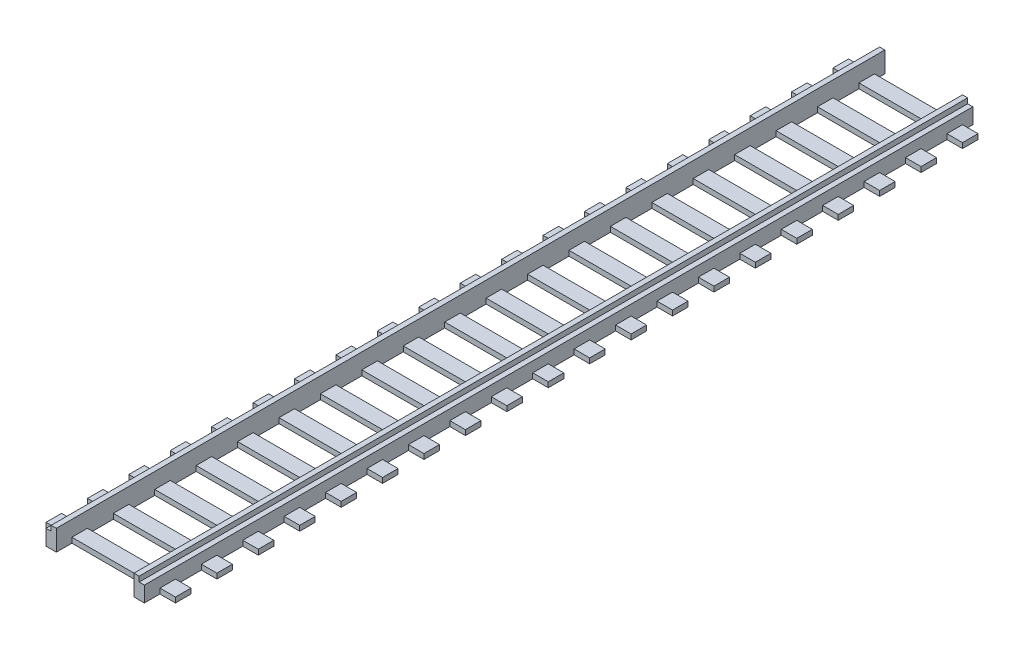
from build123d import *

# Parameters (mm, degrees)
SKETCH1_W             = 1
SKETCH1_H             = 160
BOSS_EXTRUDE1_DEPTH   = 4
BOSS_EXTRUDE1_2_DEPTH = 4
SKETCH2_W             = 1
SKETCH2_H             = 160
BOSS_EXTRUDE2_DEPTH   = 3
SKETCH3_W             = 25
SKETCH3_H             = 3
BOSS_EXTRUDE3_DEPTH   = 1


with BuildPart() as part:
    # Sketch1 → Boss-Extrude1 (new body)
    with BuildSketch(Plane(origin=(0, 0, 0), x_dir=(1, 0, 0), z_dir=(0, 1, 0))):
        with Locations((-43.187559699, -8.75)):
            Rectangle(SKETCH1_W, SKETCH1_H)
    extrude(amount=BOSS_EXTRUDE1_DEPTH)



with BuildPart() as body_2:
    # Sketch1 → Boss-Extrude1 2 (new body)
    with BuildSketch(Plane(origin=(0, 0, 0), x_dir=(1, 0, 0), z_dir=(0, 1, 0))):
        with Locations((-27.187559699, -8.75)):
            Rectangle(SKETCH1_W, SKETCH1_H)
    extrude(amount=BOSS_EXTRUDE1_2_DEPTH)


with BuildPart() as part_1:
    add(part.part)

    add(body_2.part)  # Boss-Extrude2 merges body 2
    # Sketch2 → Boss-Extrude2 (add)
    with BuildSketch(Plane.XZ):
        with Locations((-44.187559699, 8.75)):
            Rectangle(SKETCH2_W, SKETCH2_H)
        with Locations((-26.187559699, 8.75)):
            Rectangle(SKETCH2_W, SKETCH2_H)
    extrude(amount=-BOSS_EXTRUDE2_DEPTH)

    # Sketch3 → Boss-Extrude3 (add)
    with BuildSketch(Plane.XZ):
        with Locations((-35.187559699, 84.25)):
            Rectangle(SKETCH3_W, SKETCH3_H)
        with Locations((-35.187559699, 76.25)):
            Rectangle(SKETCH3_W, SKETCH3_H)
        with Locations((-35.187559699, 68.25)):
            Rectangle(SKETCH3_W, SKETCH3_H)
        with Locations((-35.187559699, 60.25)):
            Rectangle(SKETCH3_W, SKETCH3_H)
        with Locations((-35.187559699, 52.25)):
            Rectangle(SKETCH3_W, SKETCH3_H)
        with Locations((-35.187559699, 44.25)):
            Rectangle(SKETCH3_W, SKETCH3_H)
        with Locations((-35.187559699, 36.25)):
            Rectangle(SKETCH3_W, SKETCH3_H)
        with Locations((-35.187559699, 28.25)):
            Rectangle(SKETCH3_W, SKETCH3_H)
        with Locations((-35.187559699, 20.25)):
            Rectangle(SKETCH3_W, SKETCH3_H)
        with Locations((-35.187559699, 12.25)):
            Rectangle(SKETCH3_W, SKETCH3_H)
        with Locations((-35.187559699, 4.25)):
            Rectangle(SKETCH3_W, SKETCH3_H)
        with Locations((-35.187559699, -3.75)):
            Rectangle(SKETCH3_W, SKETCH3_H)
        with Locations((-35.187559699, -11.75)):
            Rectangle(SKETCH3_W, SKETCH3_H)
        with Locations((-35.187559699, -19.75)):
            Rectangle(SKETCH3_W, SKETCH3_H)
        with Locations((-35.187559699, -27.75)):
            Rectangle(SKETCH3_W, SKETCH3_H)
        with Locations((-35.187559699, -35.75)):
            Rectangle(SKETCH3_W, SKETCH3_H)
        with Locations((-35.187559699, -43.75)):
            Rectangle(SKETCH3_W, SKETCH3_H)
        with Locations((-35.187559699, -51.75)):
            Rectangle(SKETCH3_W, SKETCH3_H)
        with Locations((-35.187559699, -59.75)):
            Rectangle(SKETCH3_W, SKETCH3_H)
        with Locations((-35.187559699, -67.75)):
            Rectangle(SKETCH3_W, SKETCH3_H)
    extrude(amount=-BOSS_EXTRUDE3_DEPTH)


solid = part_1.part
